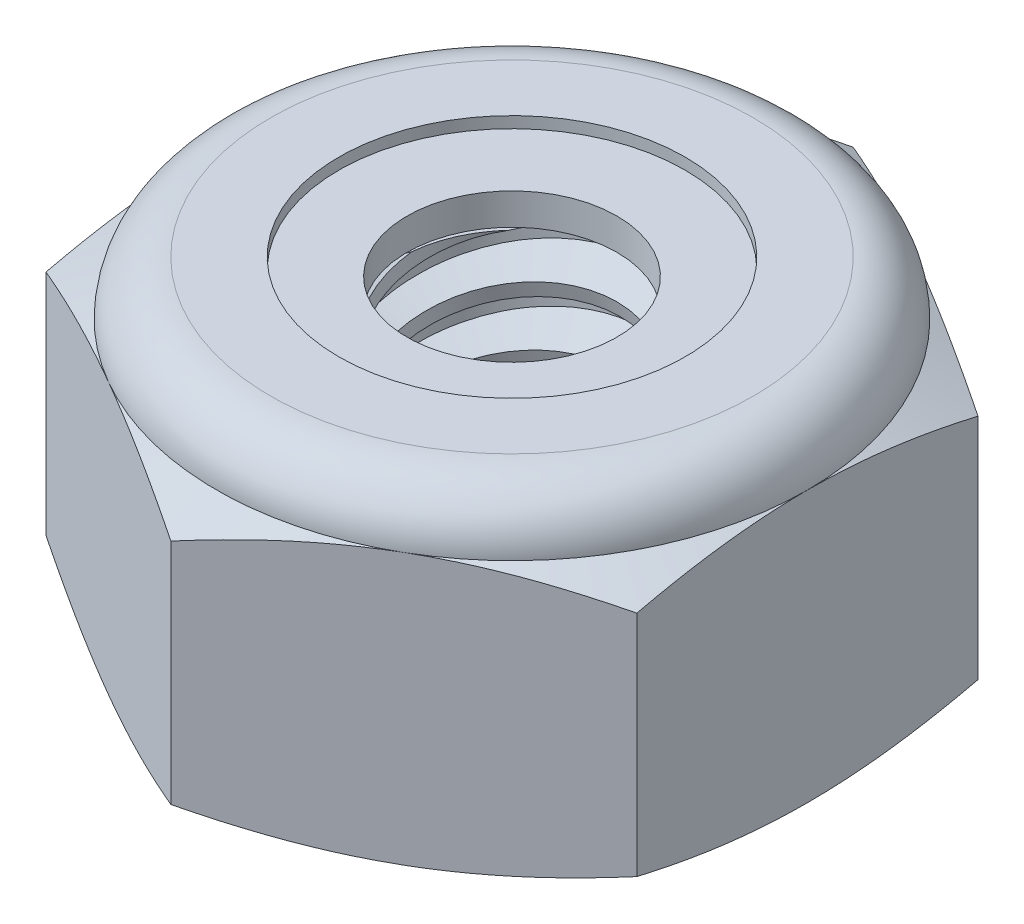
from build123d import *

# Parameters (mm, degrees)
EXTRUDE1_DEPTH      = 4.365625
SKETCH2_W           = 1.7526
SKETCH2_H           = 4.365625
LPATTERN1_COUNT     = 6
LPATTERN1_PITCH     = 0.79375
LPATTERN1_COL_COUNT = 2
LPATTERN1_COL_PITCH = 0.79375


with BuildPart() as part:
    # Sketch1 → Extrude1 (new body)
    with BuildSketch(Plane(origin=(0, 0, 0), x_dir=(1, 0, 0), z_dir=(0, 1, 0))):
        Polygon((0, 4.582717762), (-3.96875, 2.291358881), (-3.96875, -2.291358881), (0, -4.582717762), (3.96875, -2.291358881), (3.96875, 2.291358881), align=None)
    extrude(amount=EXTRUDE1_DEPTH)

    # Sketch4 → Cut-Revolve2 (revolve, cut)
    with BuildSketch(Plane(origin=(0, 0, 0), x_dir=(0, 0, -1), z_dir=(1, 0, 0))):
        Polygon((0, 4.365625), (1.7526, 4.365625), (1.410275607, 4.205996514), (1.410275607, 0.159628486), (1.7526, 0), (0, 0), align=None)
    revolve(axis=Axis((0, 4.365625, 0), (0, 1, 0)), mode=Mode.SUBTRACT)


with BuildPart() as body_2:
    # Sketch2 → Revolve1 (revolve)
    with BuildSketch(Plane(origin=(0, 0, 0), x_dir=(0, 0, -1), z_dir=(1, 0, 0))):
        with Locations((0.8763, 2.1828125)):
            Rectangle(SKETCH2_W, SKETCH2_H)
    revolve(axis=Axis((0, -1.7526, 0), (0, 1, 0)))

    # Sketch3 → Cut-Revolve1 (revolve, cut)
    with BuildSketch(Plane(origin=(0, 0, 0), x_dir=(0, 0, -1), z_dir=(1, 0, 0))):
        Polygon((1.774513192, 4.268856346), (1.927905533, 3.591475768), (1.454101991, 3.7385105), (1.410275607, 3.932047808), align=None)
    cut_revolve1 = revolve(axis=Axis((0, 4.365625, 0.193538035), (0, -0.975306119, -0.220857364)), mode=Mode.SUBTRACT)

    # LPattern1: Cut-Revolve1 ×6
    with Locations(*[(0, -i * LPATTERN1_PITCH, 0) for i in range(1, LPATTERN1_COUNT)]):
        add(cut_revolve1, mode=Mode.SUBTRACT)

    # LPattern1 col: Cut-Revolve1 ×2
    with Locations(*[(0, i * LPATTERN1_COL_PITCH, 0) for i in range(1, LPATTERN1_COL_COUNT)]):
        add(cut_revolve1, mode=Mode.SUBTRACT)


with BuildPart() as part_1:
    add(part.part)

    # Combine1: cut body 2
    add(body_2.part, mode=Mode.SUBTRACT)

    # Sketch5 → Cut-Revolve3 (revolve, cut)
    with BuildSketch(Plane(origin=(0, 0, 0), x_dir=(0, 0, -1), z_dir=(1, 0, 0))):
        with BuildLine():
            Line((0, 0), (3.96875, 0))
            Line((3.96875, 0), (4.582717762, 0.286297869))
            Line((4.582717762, 0.286297869), (4.582717762, 3.351722964))
            Line((4.582717762, 3.351722964), (3.96875, 3.638020833))
            ThreePointArc((3.96875, 3.638020833), (3.755639674, 4.152514674), (3.241145833, 4.365625))
            Line((3.241145833, 4.365625), (3.241145833, 5.635625))
            Line((3.241145833, 5.635625), (5.852717762, 5.635625))
            Line((5.852717762, 5.635625), (5.852717762, -1.27))
            Line((5.852717762, -1.27), (0, -1.27))
            Line((0, -1.27), (0, 0))
        make_face()
    revolve(axis=Axis((0, 0, 0), (0, 1, 0)), mode=Mode.SUBTRACT)

    # Sketch6 → Cut-Revolve4 (revolve, cut)
    with BuildSketch(Plane(origin=(0, 0, 0), x_dir=(0, 0, -1), z_dir=(1, 0, 0))):
        with BuildLine():
            Line((0, 3.638020833), (3.81635, 3.638020833))
            ThreePointArc((3.81635, 3.638020833), (3.6478766, 4.0447516), (3.241145833, 4.213225))
            Line((3.241145833, 4.213225), (2.32571072, 4.213225))
            Line((2.32571072, 4.213225), (2.32571072, 5.635625))
            Line((2.32571072, 5.635625), (0, 5.635625))
            Line((0, 5.635625), (0, 3.638020833))
        make_face()
    revolve(axis=Axis((0, 5.635625, 0), (0, 1, 0)), mode=Mode.SUBTRACT)


with BuildPart() as body_2_2:
    # Sketch7 → Revolve2 (revolve)
    with BuildSketch(Plane(origin=(0, 0, 0), x_dir=(0, 0, -1), z_dir=(1, 0, 0))):
        with BuildLine():
            Line((1.410275607, 3.714220833), (3.734297654, 3.714220833))
            ThreePointArc((3.734297654, 3.714220833), (3.565938876, 4.016854092), (3.241145833, 4.137025))
            Line((3.241145833, 4.137025), (1.410275607, 4.137025))
            Line((1.410275607, 4.137025), (1.410275607, 3.714220833))
        make_face()
    revolve(axis=Axis((0, 3.714220833, 0), (0, 1, 0)))


solid = Compound([part_1.part, body_2_2.part])
